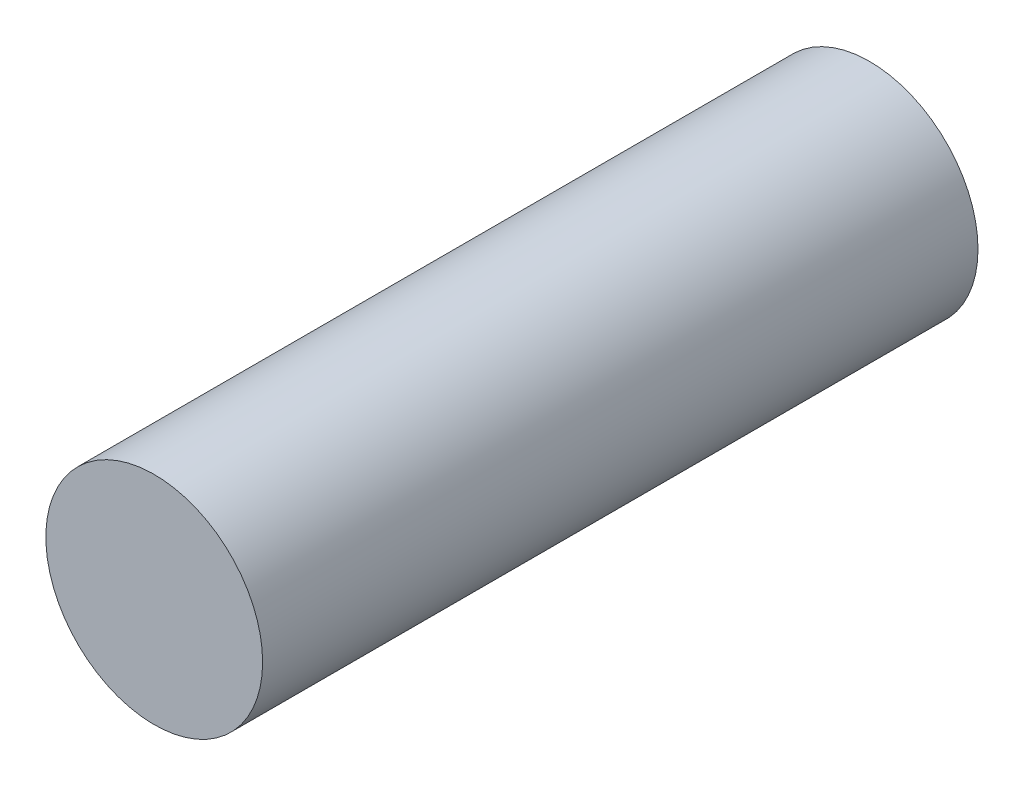
from build123d import *

# Parameters (mm, degrees)
SKETCH1_R           = 7.5
SKETCH1_R_2         = 3
BOSS_EXTRUDE1_DEPTH = 19.8
CUT_EXTRUDE1_START  = 3.9
SKETCH1_6_R         = 7.5
SKETCH1_6_R_2       = 3
CUT_EXTRUDE1_DEPTH  = 12
SKETCH1_7_R         = 7.5
SKETCH1_7_R_2       = 3
CUT_EXTRUDE5_DEPTH  = 20.8


with BuildPart() as part:
    # Sketch1 → Boss-Extrude1 (new body)
    with BuildSketch(Plane.XY):
        Circle(SKETCH1_R)
        Circle(SKETCH1_R_2, mode=Mode.SUBTRACT)
        Circle(SKETCH1_R_2)
    extrude(amount=BOSS_EXTRUDE1_DEPTH)

    # Sketch1_6 → Cut-Extrude1 (cut)
    with BuildSketch(Plane.XY.offset(CUT_EXTRUDE1_START)):
        Circle(SKETCH1_6_R)
        Circle(SKETCH1_6_R_2, mode=Mode.SUBTRACT)
    extrude(amount=CUT_EXTRUDE1_DEPTH, mode=Mode.SUBTRACT)

    # Sketch1_7 → Cut-Extrude5 (cut, through all)
    with BuildSketch(Plane.XY):
        Circle(SKETCH1_7_R)
        Circle(SKETCH1_7_R_2, mode=Mode.SUBTRACT)
    extrude(amount=CUT_EXTRUDE5_DEPTH, mode=Mode.SUBTRACT)


solid = part.part
